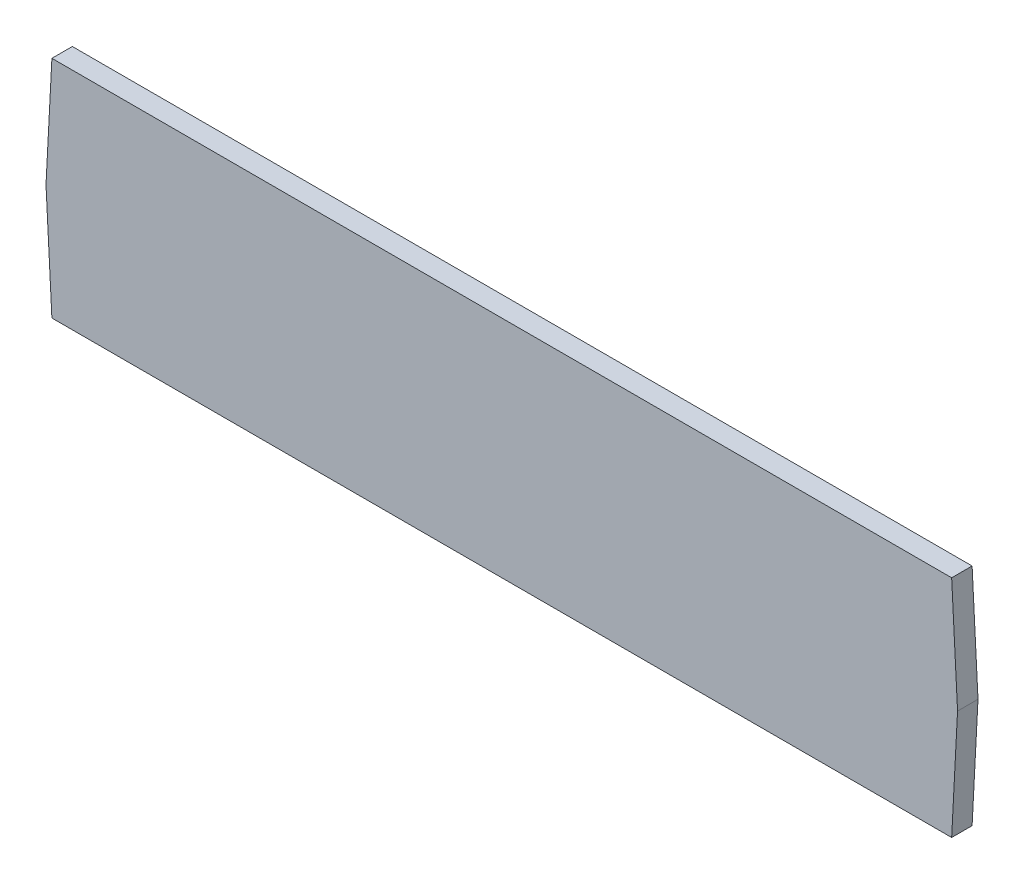
from build123d import *

# Parameters (mm, degrees)
BOSS_EXTRUDE1_DEPTH = 3


with BuildPart() as part:
    # Sketch1 → Boss-Extrude1 (new body)
    with BuildSketch(Plane.XY):
        Polygon((0, 0), (132, 0), (132.864728358, -16.500000002), (132, -33.000000002), (0, -33.000000002), (-0.864728358, -16.500000001), align=None)
    extrude(amount=BOSS_EXTRUDE1_DEPTH)


solid = part.part
